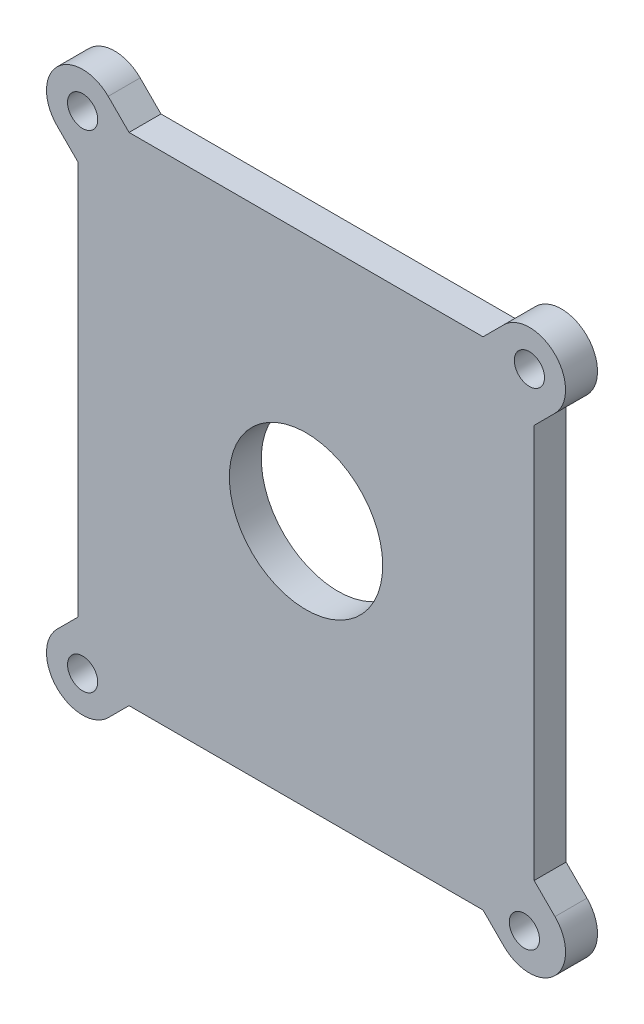
from build123d import *

# Parameters (mm, degrees)
SKETCH1_R               = 11.43
BOSS_EXTRUDE1_DEPTH     = 4.7625
MIRROR2_COPY_1_SKETCH_R = 11.43
MIRROR2_COPY_1_DEPTH    = 4.7625
M4_CLEARANCE_HOLE2_D    = 4.5


with BuildPart() as part:
    # Sketch1 → Boss-Extrude1 (new body)
    with BuildSketch(Plane.XY):
        with BuildLine():
            Line((33.9979, -29.3751), (33.9979, 36.9951))
            Line((33.9979, 36.9951), (-33.9979, 36.9951))
            Line((-33.9979, 36.9951), (-33.9979, -36.9951))
            Line((-33.9979, -36.9951), (26.3779, -36.9951))
            Line((26.3779, -36.9951), (29.48387433, -40.10107433))
            ThreePointArc((29.48387433, -40.10107433), (37.10387433, -40.10107433), (37.10387433, -32.48107433))
            Line((37.10387433, -32.48107433), (33.9979, -29.3751))
        make_face()
        Circle(SKETCH1_R, mode=Mode.SUBTRACT)
        Polygon((33.926365892, -36.9951), (33.9979, -36.923565892), (33.9979, -36.9951), align=None, mode=Mode.SUBTRACT)
    boss_extrude1 = extrude(amount=BOSS_EXTRUDE1_DEPTH)

    # Mirror1: Boss-Extrude1 across plane
    add(boss_extrude1.mirror(Plane.ZX))

    # Mirror2: Boss-Extrude1 across plane
    add(boss_extrude1.mirror(Plane(origin=(0, 0, 0), x_dir=(0, 0, 1), z_dir=(1, 0, 0))))

    # Mirror2 copy 1 sketch → Mirror2 copy 1 (add)
    with BuildSketch(Plane(origin=(0, 0, 0), x_dir=(-1, 0, 0), z_dir=(0, 0, 1))):
        with BuildLine():
            Line((33.9979, -29.3751), (33.9979, 36.9951))
            Line((33.9979, 36.9951), (-33.9979, 36.9951))
            Line((-33.9979, 36.9951), (-33.9979, -36.9951))
            Line((-33.9979, -36.9951), (26.3779, -36.9951))
            Line((26.3779, -36.9951), (29.48387433, -40.10107433))
            ThreePointArc((29.48387433, -40.10107433), (37.10387433, -40.10107433), (37.10387433, -32.48107433))
            Line((37.10387433, -32.48107433), (33.9979, -29.3751))
        make_face()
        Circle(MIRROR2_COPY_1_SKETCH_R, mode=Mode.SUBTRACT)
        Polygon((33.926365892, -36.9951), (33.9979, -36.923565892), (33.9979, -36.9951), align=None, mode=Mode.SUBTRACT)
    extrude(amount=MIRROR2_COPY_1_DEPTH)

    # M4 Clearance Hole2 (through all)
    with Locations(Plane.XY.offset(4.7625)):
        with Locations((-33.29387433, 36.29107433), (33.29387433, 36.29107433), (32.547164682, -36.586652732), (-33.29387433, -36.29107433)):
            Hole(M4_CLEARANCE_HOLE2_D / 2)


solid = part.part
